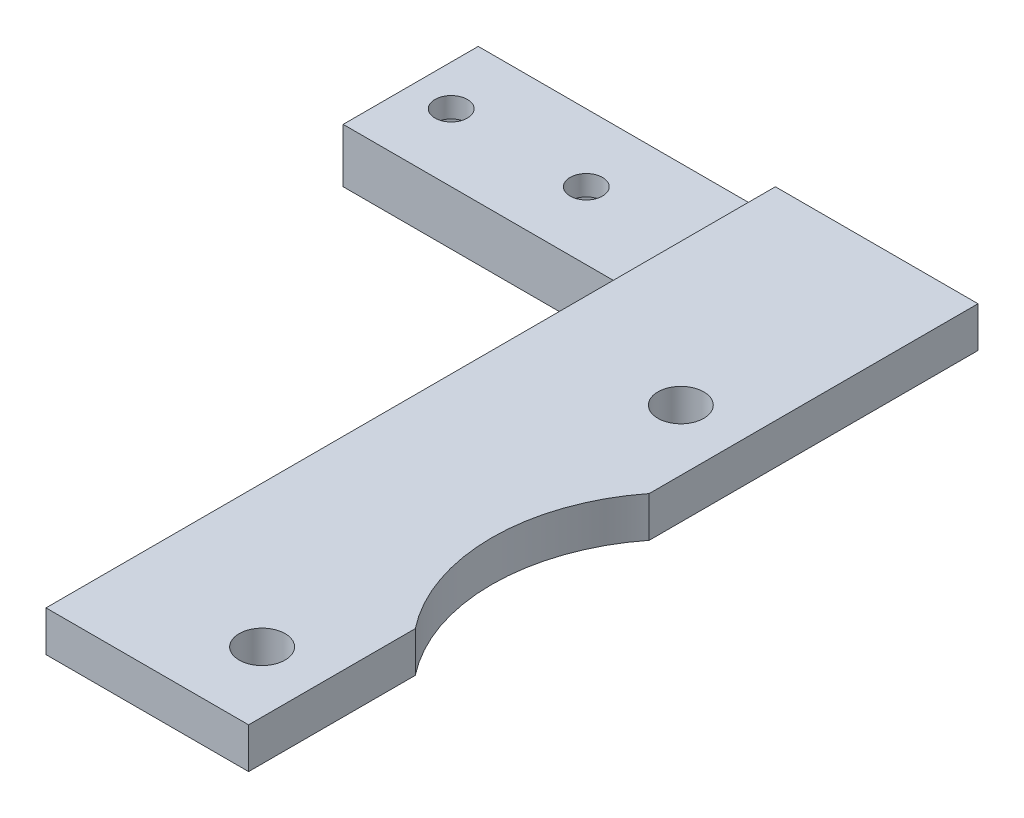
from build123d import *

# Parameters (mm, degrees)
SALIENTE_EXTRUIR1_DEPTH = 10
CROQUIS2_W              = 15
CROQUIS2_H              = 3
SALIENTE_EXTRUIR2_DEPTH = 44
CROQUIS3_R              = 14
CROQUIS3_R_2            = 1.7
CORTAR_EXTRUIR1_DEPTH   = 44
CROQUIS4_R              = 1.2
CORTAR_EXTRUIR2_DEPTH   = 5
CORTAR_EXTRUIR3_DEPTH   = 2.5


with BuildPart() as part:
    # Croquis1 → Saliente-Extruir1 (new body)
    with BuildSketch(Plane.XY):
        with BuildLine():
            Line((0, 4), (0, 0))
            Line((0, 0), (24, 0))
            ThreePointArc((24, 0), (24.707106781, 0.292893219), (25, 1))
            Line((25, 1), (25, 2))
            ThreePointArc((25, 2), (25.292893219, 2.707106781), (26, 3))
            Line((26, 3), (37, 3))
            Line((37, 3), (37, 6))
            Line((37, 6), (22, 6))
            Line((22, 6), (22, 5))
            ThreePointArc((22, 5), (21.707106781, 4.292893219), (21, 4))
            Line((21, 4), (0, 4))
        make_face()
    extrude(amount=SALIENTE_EXTRUIR1_DEPTH)

    # Croquis2 → Saliente-Extruir2 (add)
    with BuildSketch(Plane.XY.offset(10)):
        with Locations((29.5, 4.5)):
            Rectangle(CROQUIS2_W, CROQUIS2_H)
    extrude(amount=SALIENTE_EXTRUIR2_DEPTH)

    # Croquis3 → Cortar-Extruir1 (cut)
    with BuildSketch(Plane(origin=(0, 6, 0), x_dir=(1, 0, 0), z_dir=(0, 1, 0))):
        with Locations((48, -33)):
            Circle(CROQUIS3_R)
        with Locations((32.5, -17.5)):
            Circle(CROQUIS3_R_2)
        with Locations((32.5, -48.5)):
            Circle(CROQUIS3_R_2)
    extrude(amount=-CORTAR_EXTRUIR1_DEPTH, mode=Mode.SUBTRACT)

    # Croquis4 → Cortar-Extruir2 (cut)
    with BuildSketch(Plane(origin=(0, 4, 0), x_dir=(1, 0, 0), z_dir=(0, 1, 0))):
        with Locations((13, -5)):
            Circle(CROQUIS4_R)
        with Locations((3, -5)):
            Circle(CROQUIS4_R)
    extrude(amount=-CORTAR_EXTRUIR2_DEPTH, mode=Mode.SUBTRACT)

    # Croquis5 → Cortar-Extruir3 (cut)
    with BuildSketch(Plane.XZ):
        Polygon((3, 7.25), (1.051442841, 6.125), (1.051442841, 3.875), (3, 2.75), (4.948557159, 3.875), (4.948557159, 6.125), align=None)
        Polygon((13, 7.25), (11.051442841, 6.125), (11.051442841, 3.875), (13, 2.75), (14.948557159, 3.875), (14.948557159, 6.125), align=None)
    extrude(amount=-CORTAR_EXTRUIR3_DEPTH, mode=Mode.SUBTRACT)


solid = part.part
